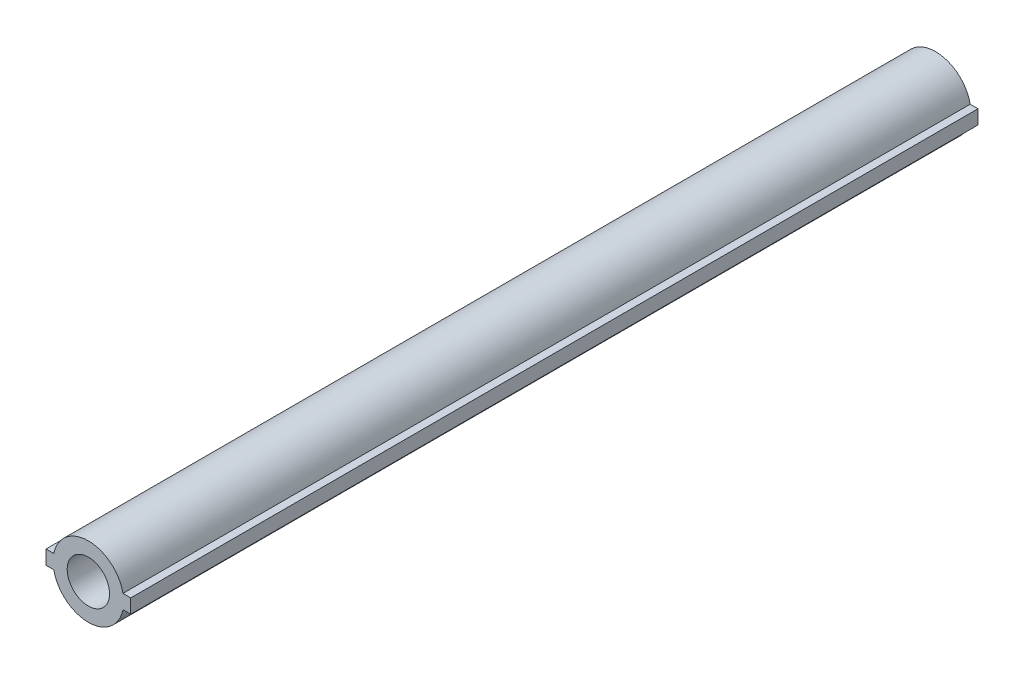
from build123d import *

# Parameters (mm, degrees)
SKETCH1_R           = 750
BOSS_EXTRUDE1_DEPTH = 18000
SKETCH2_W           = 1800
SKETCH2_H           = 300
BOSS_EXTRUDE2_DEPTH = 18000
CUT_EXTRUDE1_START  = -18000
SKETCH3_R           = 450
CUT_EXTRUDE1_DEPTH  = 12000


with BuildPart() as part:
    # Sketch1 → Boss-Extrude1 (new body)
    with BuildSketch(Plane.XY):
        Circle(SKETCH1_R)
    extrude(amount=BOSS_EXTRUDE1_DEPTH)

    # Sketch2 → Boss-Extrude2 (add)
    with BuildSketch(Plane.XY.offset(18000)):
        Rectangle(SKETCH2_W, SKETCH2_H)
    extrude(amount=-BOSS_EXTRUDE2_DEPTH)

    # Sketch3 → Cut-Extrude1 (cut)
    with BuildSketch(Plane(origin=(0, 0, 0), x_dir=(-1, 0, 0), z_dir=(0, 0, -1)).offset(CUT_EXTRUDE1_START)):
        Circle(SKETCH3_R)
    extrude(amount=CUT_EXTRUDE1_DEPTH, mode=Mode.SUBTRACT)


solid = part.part
